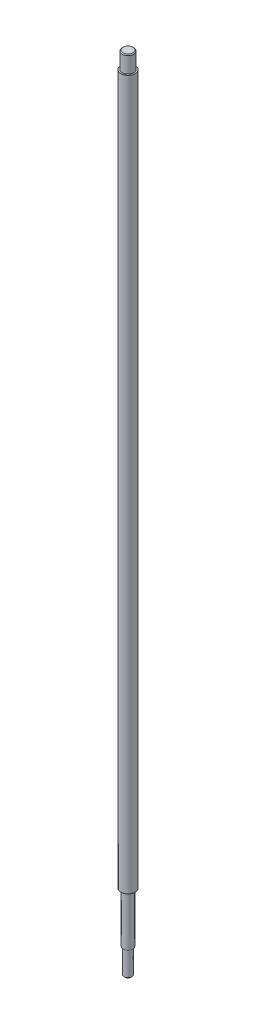
from build123d import *

# Parameters (mm, degrees)
SKETCH4_R           = 4.266666667
BOSS_EXTRUDE1_DEPTH = 421
SKETCH5_R           = 3.413333333
BOSS_EXTRUDE2_DEPTH = 10
CHAMFER1_SIZE       = 0.5
SKETCH6_R           = 2.844444444
BOSS_EXTRUDE3_DEPTH = 30
SKETCH7_R           = 2.275555556
BOSS_EXTRUDE4_DEPTH = 15
CHAMFER2_SIZE       = 0.5
SCALE1_SCALE        = 7.5


with BuildPart() as part:
    # Sketch4 → Boss-Extrude1 (new body)
    with BuildSketch(Plane(origin=(0, 0, 0), x_dir=(1, 0, 0), z_dir=(0, 1, 0))):
        Circle(SKETCH4_R)
    extrude(amount=BOSS_EXTRUDE1_DEPTH)

    # Sketch5 → Boss-Extrude2 (add)
    with BuildSketch(Plane(origin=(0, 421, 0), x_dir=(1, 0, 0), z_dir=(0, 1, 0))):
        Circle(SKETCH5_R)
    extrude(amount=BOSS_EXTRUDE2_DEPTH)

    # Chamfer1
    chamfer1_edges = [part.edges().sort_by_distance(p)[0] for p in [
        (-3.413333333, 431, 0),
    ]]
    chamfer(chamfer1_edges, length=CHAMFER1_SIZE)

    # Sketch6 → Boss-Extrude3 (add)
    with BuildSketch(Plane.XZ):
        Circle(SKETCH6_R)
    extrude(amount=BOSS_EXTRUDE3_DEPTH)

    # Sketch7 → Boss-Extrude4 (add)
    with BuildSketch(Plane.XZ.offset(30)):
        Circle(SKETCH7_R)
    extrude(amount=BOSS_EXTRUDE4_DEPTH)

    # Chamfer2
    chamfer2_edges = [part.edges().sort_by_distance(p)[0] for p in [
        (-2.275555556, -45, 0),
    ]]
    chamfer(chamfer2_edges, length=CHAMFER2_SIZE)


with BuildPart() as part_1:
    # Scale1: scaled about (0, 204.458486732, 0)
    add(part.part.scale(SCALE1_SCALE).moved(Location((0, -1328.980163758, 0))))


solid = part_1.part
